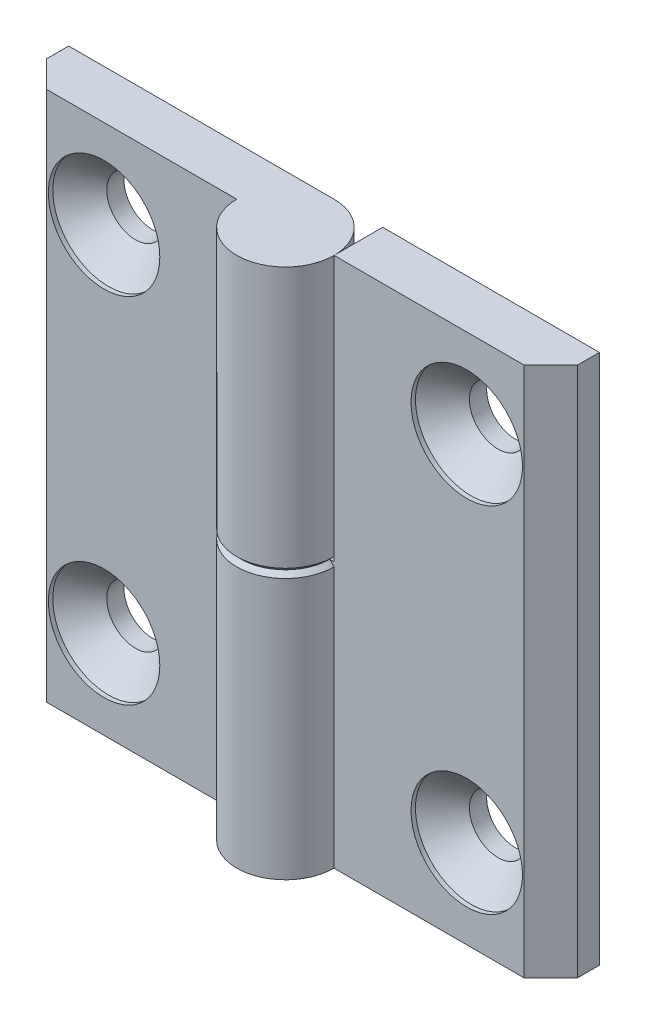
from build123d import *

# Parameters (mm, degrees)
EXTRUDE_1_DEPTH            = 30
SKETCH_3_W                 = 11
SKETCH_3_H                 = 30
CUT_EXTRUDE_1_DEPTH        = 6.5
CUT_EXTRUDE_1_DEPTH_BACK   = 6.5
HOLE_WIZARD_M61_AT_2_COUNT = 2
HOLE_WIZARD_M61_AT_2_PITCH = 40
CHAMFER_1_SIZE             = 0.5
PATTERN_CIRCULAR_1_COUNT   = 2


with BuildPart() as part:
    # Эскиз1 → Бобышка-Вытянуть1 (new body, symmetric)
    with BuildSketch(Plane(origin=(0, 0, 0), x_dir=(1, 0, 0), z_dir=(0, 1, 0))):
        with BuildLine():
            Line((0, 5.5), (-30, 5.5))
            Line((-30, 5.5), (-30, 3))
            Line((-30, 3), (-27, 0))
            Line((-27, 0), (-5.5, 0))
            ThreePointArc((-5.5, 0), (3.889087297, -3.889087297), (0, 5.5))
        make_face()
    extrude(amount=EXTRUDE_1_DEPTH, both=True)

    # Эскиз3 → Вырез-Вытянуть1 (cut, two sides)
    with BuildSketch(Plane.XY) as cut_extrude_1_sk:
        with Locations((0, -15)):
            Rectangle(SKETCH_3_W, SKETCH_3_H)
    extrude(amount=CUT_EXTRUDE_1_DEPTH, mode=Mode.SUBTRACT)
    extrude(cut_extrude_1_sk.sketch, amount=-CUT_EXTRUDE_1_DEPTH_BACK, mode=Mode.SUBTRACT)

    # Эскиз6 → Зенковка для винта с полупотайной головкой M61 (revolve, cut)
    with BuildSketch(Plane(origin=(-20.5, 20, 0), x_dir=(0, -1, 0), z_dir=(1, 0, 0))):
        Polygon((0, 0), (0, 5.5), (3.25, 5.5), (3.25, 3.55), (6.3, 0.5), (6.3, 0), align=None)
    hole_wizard_m61 = revolve(axis=Axis((-20.5, 20, 6.35), (0, 0, -1)), mode=Mode.SUBTRACT)

    # Зенковка для винта с полупотайной головкой M61 at 2: Зенковка для винта с полупотайной головкой M61 ×2
    with Locations(*[(0, -i * HOLE_WIZARD_M61_AT_2_PITCH, 0) for i in range(1, HOLE_WIZARD_M61_AT_2_COUNT)]):
        add(hole_wizard_m61, mode=Mode.SUBTRACT)

    # Фаска1
    chamfer_1_edges = [part.edges().sort_by_distance(p)[0] for p in [
        (3.889087297, 0, 3.889087297),
        (-2.75, 0, -5.5),
    ]]
    chamfer(chamfer_1_edges, length=CHAMFER_1_SIZE)


with BuildPart() as pattern_circular_1_1:
    # Круговой массив1: pattern copy
    add(part.part.rotate(Axis((0, 0, 0), (0, 0, 1)), 1 * 360 / PATTERN_CIRCULAR_1_COUNT))


solid = Compound([part.part, pattern_circular_1_1.part])
